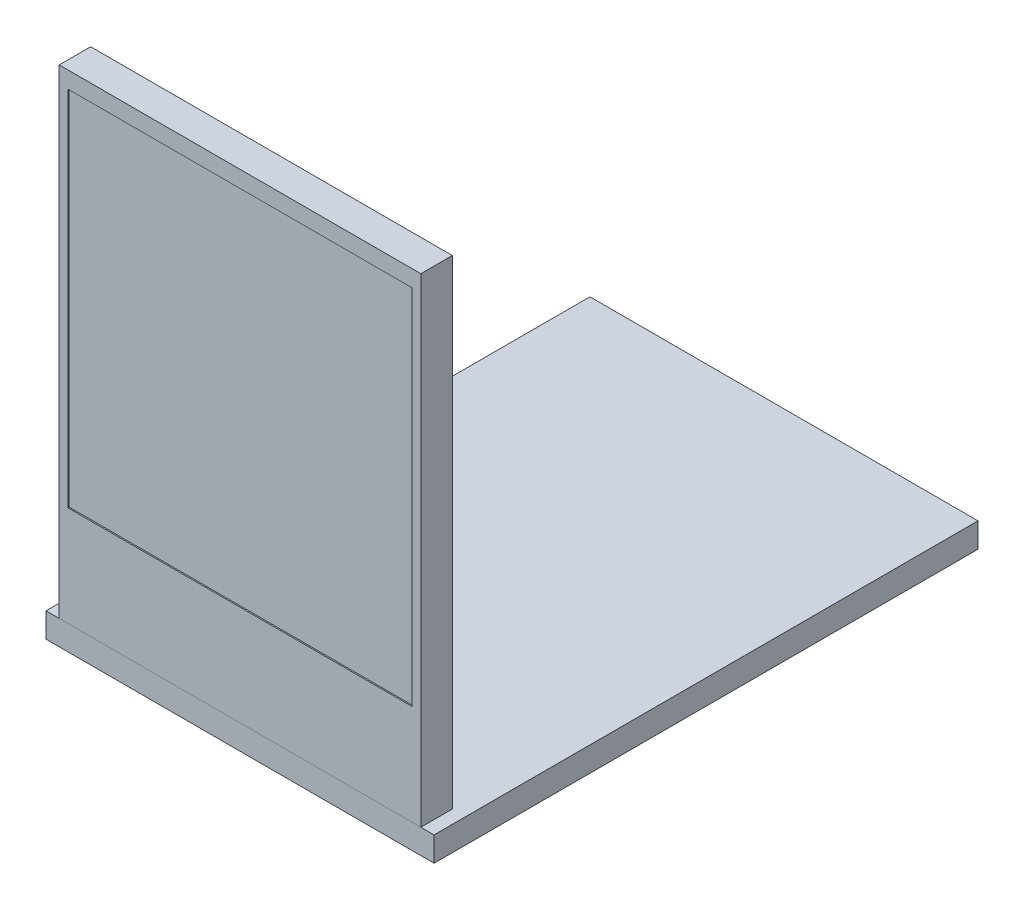
from build123d import *

# Parameters (mm, degrees)
SKETCH1_W           = 31.57
SKETCH1_H           = 44.25
BOSS_EXTRUDE1_DEPTH = 2
SKETCH2_W           = 29.42
SKETCH2_H           = 39
BOSS_EXTRUDE2_DEPTH = 2.56
SKETCH3_W           = 28
SKETCH3_H           = 29.5
CUT_EXTRUDE1_DEPTH  = 0.1


with BuildPart() as part:
    # Sketch1 → Boss-Extrude1 (new body)
    with BuildSketch(Plane(origin=(0, 0, 0), x_dir=(1, 0, 0), z_dir=(0, 1, 0))):
        with Locations((0, 22.125)):
            Rectangle(SKETCH1_W, SKETCH1_H)
    extrude(amount=-BOSS_EXTRUDE1_DEPTH)


with BuildPart() as body_2:
    # Sketch2 → Boss-Extrude2 (new body)
    with BuildSketch(Plane.XY):
        with Locations((0, 19.5)):
            Rectangle(SKETCH2_W, SKETCH2_H)
    extrude(amount=-BOSS_EXTRUDE2_DEPTH)

    # Sketch3 → Cut-Extrude1 (cut)
    with BuildSketch(Plane.XY):
        with Locations((0, 22.9)):
            Rectangle(SKETCH3_W, SKETCH3_H)
    extrude(amount=-CUT_EXTRUDE1_DEPTH, mode=Mode.SUBTRACT)


solid = Compound([part.part, body_2.part])
